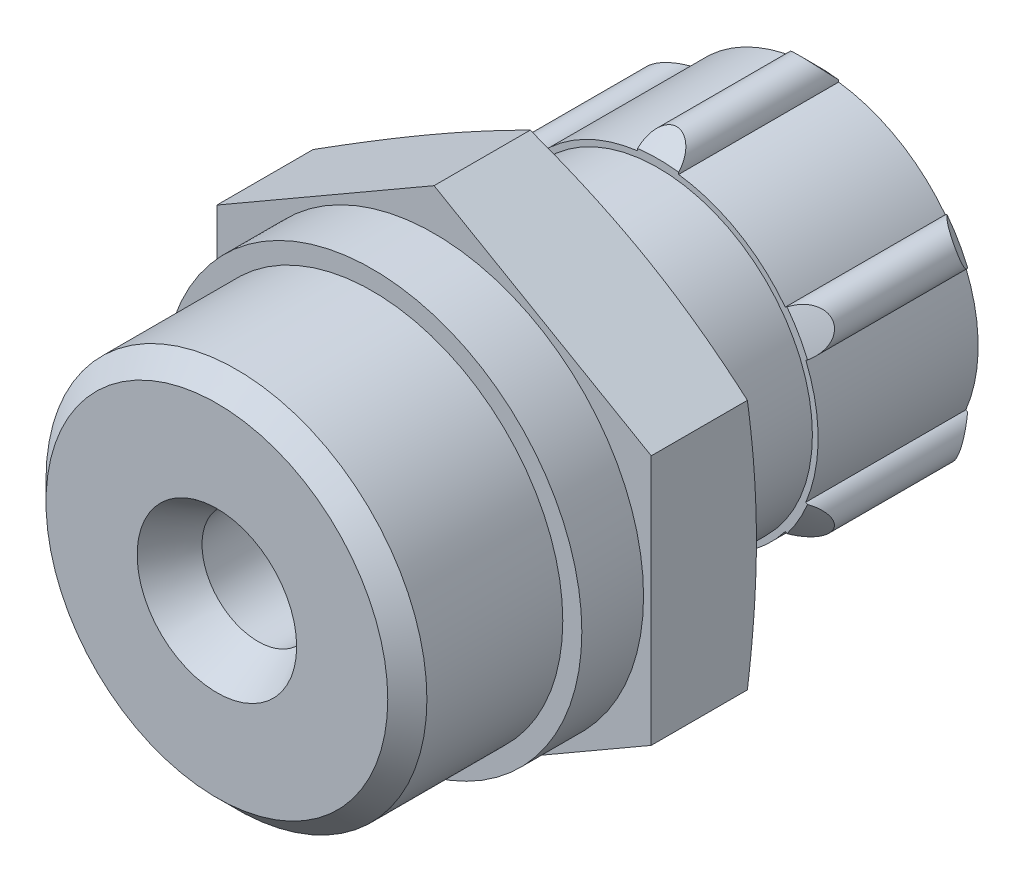
from build123d import *

# Parameters (mm, degrees)
SKETCH1_W           = 11
SKETCH1_H           = 6.75
SKETCH3_R           = 6.075
BOSS_EXTRUDE1_DEPTH = 7
SKETCH6_W           = 38
SKETCH6_H           = 38
CUT_EXTRUDE1_DEPTH  = 4.6


with BuildPart() as part:
    # Sketch1 → Revolve1 (revolve)
    with BuildSketch(Plane(origin=(0, 0, 0), x_dir=(0, 0, -1), z_dir=(1, 0, 0))):
        with Locations((20.8, 3.375)):
            Rectangle(SKETCH1_W, SKETCH1_H)
    revolve(axis=Axis((0, 0, -26.3), (0, 0, 1)))

    # Sketch2 → Cut-Revolve1 (revolve, cut)
    with BuildSketch(Plane(origin=(0, 0, 0), x_dir=(0, 0, -1), z_dir=(1, 0, 0))):
        Polygon((15.3, 0), (15.3, 6), (15.8415, 5.4585), (24.3, 5.4585), (25.6085, 4.15), (26.3, 4.15), (26.3, 0), align=None)
    revolve(axis=Axis((0, 0, -26.3), (0, 0, 1)), mode=Mode.SUBTRACT)

    # Sketch3 → Boss-Extrude1 (add)
    with BuildSketch(Plane.XY.offset(-19.3)):
        with BuildLine():
            ThreePointArc((-6.461141261, 2.693260775), (-7, 0), (-6.461141261, -2.693260775))
            ThreePointArc((-6.461141261, -2.693260775), (-6.84160069, -3.95), (-5.563002881, -4.248882082))
            ThreePointArc((-5.563002881, -4.248882082), (-3.5, -6.062177826), (-0.898138381, -6.942142857))
            ThreePointArc((-0.898138381, -6.942142857), (0, -7.9), (0.898138381, -6.942142857))
            ThreePointArc((0.898138381, -6.942142857), (3.5, -6.062177826), (5.563002881, -4.248882082))
            ThreePointArc((5.563002881, -4.248882082), (6.84160069, -3.95), (6.461141261, -2.693260775))
            ThreePointArc((6.461141261, -2.693260775), (7, 0), (6.461141261, 2.693260775))
            ThreePointArc((6.461141261, 2.693260775), (6.84160069, 3.95), (5.563002881, 4.248882082))
            ThreePointArc((5.563002881, 4.248882082), (3.5, 6.062177826), (0.898138381, 6.942142857))
            ThreePointArc((0.898138381, 6.942142857), (0, 7.9), (-0.898138381, 6.942142857))
            ThreePointArc((-0.898138381, 6.942142857), (-3.5, 6.062177826), (-5.563002881, 4.248882082))
            ThreePointArc((-5.563002881, 4.248882082), (-6.84160069, 3.95), (-6.461141261, 2.693260775))
        make_face()
        Circle(SKETCH3_R, mode=Mode.SUBTRACT)
    extrude(amount=-BOSS_EXTRUDE1_DEPTH)

    # Sketch4 → Cut-Revolve2 (revolve, cut)
    with BuildSketch(Plane(origin=(0, 0, 0), x_dir=(0, 0, -1), z_dir=(1, 0, 0))):
        Polygon((18.3, 20.5875), (18.3, 7.0875), (19.3, 7.0875), (22.8, 10.5875), (27.3, 6.0875), (27.3, 20.5875), align=None)
    revolve(axis=Axis((0, 0, -27.3), (0, 0, 1)), mode=Mode.SUBTRACT)

    # Sketch5 → Revolve2 (revolve)
    with BuildSketch(Plane(origin=(0, 0, 0), x_dir=(0, 0, -1), z_dir=(1, 0, 0))):
        with BuildLine():
            Line((0, 0), (0, 7.475))
            Line((0, 7.475), (0.856, 8.331))
            Line((0.856, 8.331), (6.8, 8.331))
            Line((6.8, 8.331), (6.8, 9.1641))
            Line((6.8, 9.1641), (9.5, 9.1641))
            Line((9.5, 9.1641), (9.5, 11.4))
            Line((9.5, 11.4), (13.590896534, 11.4))
            Line((13.590896534, 11.4), (14.1, 9.5))
            Line((14.1, 9.5), (14.1, 6.4))
            ThreePointArc((14.1, 6.4), (14.217157288, 6.117157288), (14.5, 6))
            Line((14.5, 6), (20.1, 6))
            Line((20.1, 6), (21.1, 5))
            Line((21.1, 5), (21.1, 3.6))
            ThreePointArc((21.1, 3.6), (21.158578644, 3.458578644), (21.3, 3.4))
            Line((21.3, 3.4), (25, 3.4))
            ThreePointArc((25, 3.4), (25.085169797, 3.587965433), (25.282648033, 3.647859044))
            Line((25.282648033, 3.647859044), (27.2, 2.95))
            Line((27.2, 2.95), (28, 2.95))
            ThreePointArc((28, 2.95), (28.212132034, 2.862132034), (28.3, 2.65))
            Line((28.3, 2.65), (28.3, 0))
            Line((28.3, 0), (0, 0))
        make_face()
    revolve(axis=Axis((0, 0, -28.3), (0, 0, 1)))

    # Sketch6 → Cut-Extrude1 (cut)
    with BuildSketch(Plane.XY.offset(-14.1)):
        Rectangle(SKETCH6_W, SKETCH6_H)
        Polygon((-9.5, 5.484827557), (-9.5, -5.484827557), (0, -10.969655115), (9.5, -5.484827557), (9.5, 5.484827557), (0, 10.969655115), align=None, mode=Mode.SUBTRACT)
    extrude(amount=CUT_EXTRUDE1_DEPTH, mode=Mode.SUBTRACT)

    # Sketch7 → Cut-Revolve3 (revolve, cut)
    with BuildSketch(Plane(origin=(0, 0, 0), x_dir=(0, 0, -1), z_dir=(1, 0, 0))):
        Polygon((0, 0), (0, 3.489230485), (1.8, 2.45), (28.3, 2.45), (28.3, 0), align=None)
    revolve(axis=Axis((0, 0, -28.3), (0, 0, 1)), mode=Mode.SUBTRACT)


solid = part.part
